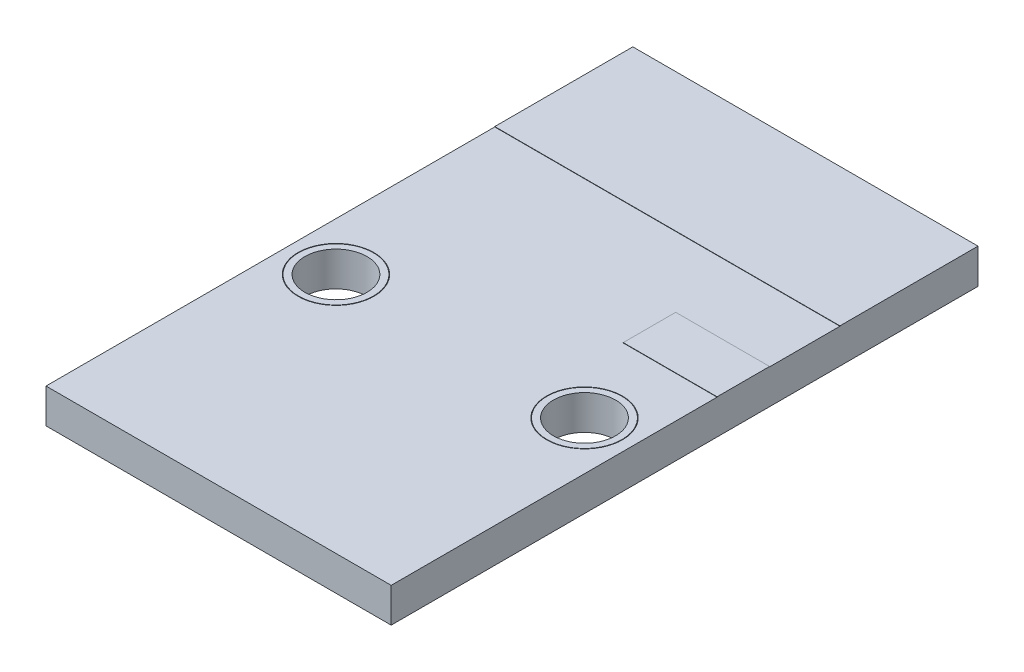
from build123d import *

# Parameters (mm, degrees)
SKETCH_3_W          = 10
SKETCH_3_H          = 17
EXTRUDE_2_DEPTH     = 1
SKETCH_4_R          = 1.1
CUT_EXTRUDE_1_DEPTH = 1
SKETCH_7_R          = 1.085736063
SKETCH_7_R_2        = 0.9
EXTRUDE_3_DEPTH     = 1
SKETCH_7_R_3        = 1.085426327
EXTRUDE_3_2_DEPTH   = 1
SKETCH_8_W          = 10
SKETCH_8_H          = 4
EXTRUDE_4_DEPTH     = 0.01
SKETCH_9_W          = 2.718788434
SKETCH_9_H          = 1.519981135
EXTRUDE_5_DEPTH     = 0.01


with BuildPart() as part:
    # 草图3 → 凸台-拉伸2 (new body)
    with BuildSketch(Plane(origin=(0, 0, 0), x_dir=(1, 0, 0), z_dir=(0, 1, 0))):
        with Locations((5, -8.5)):
            Rectangle(SKETCH_3_W, SKETCH_3_H)
    extrude(amount=EXTRUDE_2_DEPTH)

    # 草图4 → 切除-拉伸1 (cut)
    with BuildSketch(Plane(origin=(0, 1, 0), x_dir=(1, 0, 0), z_dir=(0, 1, 0))):
        with Locations((1.4, -10)):
            Circle(SKETCH_4_R)
        with Locations((8.6, -10)):
            Circle(SKETCH_4_R)
    extrude(amount=-CUT_EXTRUDE_1_DEPTH, mode=Mode.SUBTRACT)

    # 草图8 → 凸台-拉伸4 (add)
    with BuildSketch(Plane(origin=(0, 1, 0), x_dir=(1, 0, 0), z_dir=(0, 1, 0))):
        with Locations((5, -2)):
            Rectangle(SKETCH_8_W, SKETCH_8_H)
    extrude(amount=EXTRUDE_4_DEPTH)

    # 草图9 → 凸台-拉伸5 (add)
    with BuildSketch(Plane(origin=(0, 1, 0), x_dir=(1, 0, 0), z_dir=(0, 1, 0))):
        with Locations((8.640605783, -6.798698645)):
            Rectangle(SKETCH_9_W, SKETCH_9_H)
    extrude(amount=EXTRUDE_5_DEPTH)


with BuildPart() as body_2:
    # 草图7 → 凸台-拉伸3 (new body)
    with BuildSketch(Plane(origin=(0, 1, 0), x_dir=(1, 0, 0), z_dir=(0, 1, 0))):
        with Locations((8.6, -10)):
            Circle(SKETCH_7_R)
        with Locations((8.6, -10)):
            Circle(SKETCH_7_R_2, mode=Mode.SUBTRACT)
    extrude(amount=-EXTRUDE_3_DEPTH)


with BuildPart() as body_3:
    # 草图7 → Extrude 3 2 (new body)
    with BuildSketch(Plane(origin=(0, 1, 0), x_dir=(1, 0, 0), z_dir=(0, 1, 0))):
        with Locations((1.4, -10)):
            Circle(SKETCH_7_R_3)
        with Locations((1.4, -10)):
            Circle(SKETCH_7_R_2, mode=Mode.SUBTRACT)
    extrude(amount=-EXTRUDE_3_2_DEPTH)


solid = Compound([part.part, body_2.part, body_3.part])
